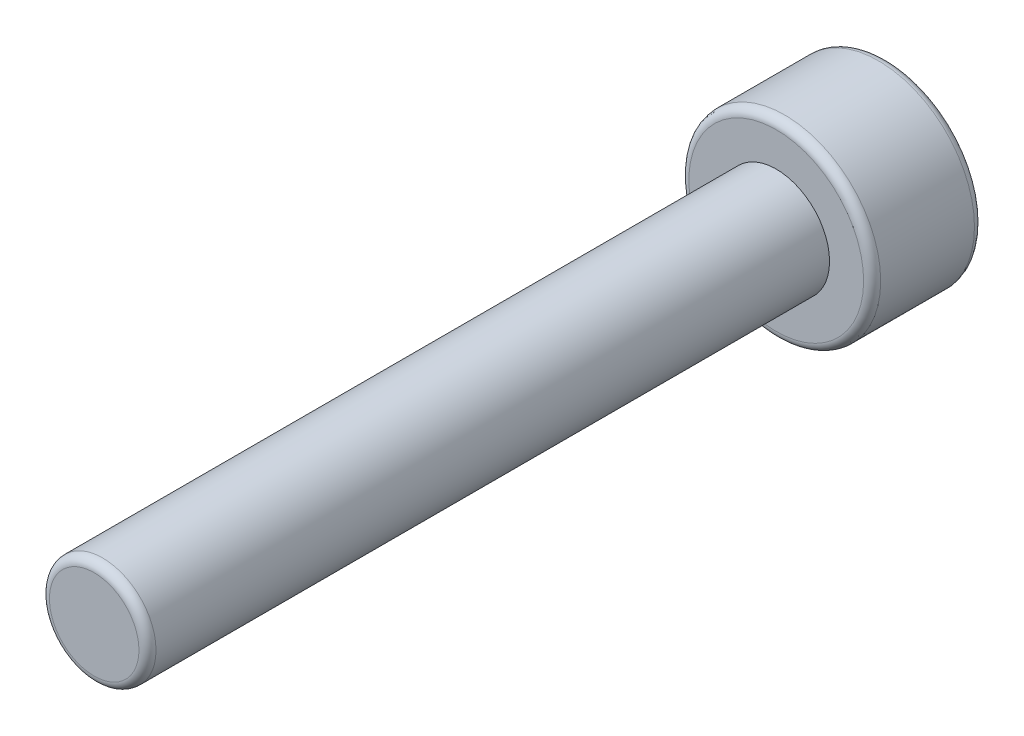
from build123d import *

# Parameters (mm, degrees)
SKETCH1_R           = 1.25
BOSS_EXTRUDE1_DEPTH = 16
SKETCH1_3_R         = 2.25
BOSS_EXTRUDE2_DEPTH = 2.6
CUT_EXTRUDE1_DEPTH  = 1.4
FILLET1_R           = 0.2


with BuildPart() as part:
    # Sketch1 → Boss-Extrude1 (new body)
    with BuildSketch(Plane.XY):
        Circle(SKETCH1_R)
    extrude(amount=BOSS_EXTRUDE1_DEPTH)

    # Sketch1_3 → Boss-Extrude2 (add)
    with BuildSketch(Plane.XY):
        Circle(SKETCH1_3_R)
    extrude(amount=-BOSS_EXTRUDE2_DEPTH)

    # Sketch2 → Cut-Extrude1 (cut)
    with BuildSketch(Plane(origin=(0, 0, -2.6), x_dir=(-1, 0, 0), z_dir=(0, 0, -1))):
        Polygon((0, 1.154700538), (-1, 0.577350269), (-1, -0.577350269), (0, -1.154700538), (1, -0.577350269), (1, 0.577350269), align=None)
    extrude(amount=-CUT_EXTRUDE1_DEPTH, mode=Mode.SUBTRACT)

    # Fillet1
    fillet1_edges = [part.edges().sort_by_distance(p)[0] for p in [
        (-1.25, 0, 16),
        (-2.25, 0, 0),
        (-2.25, 0, -2.6),
    ]]
    fillet(fillet1_edges, radius=FILLET1_R)


solid = part.part
